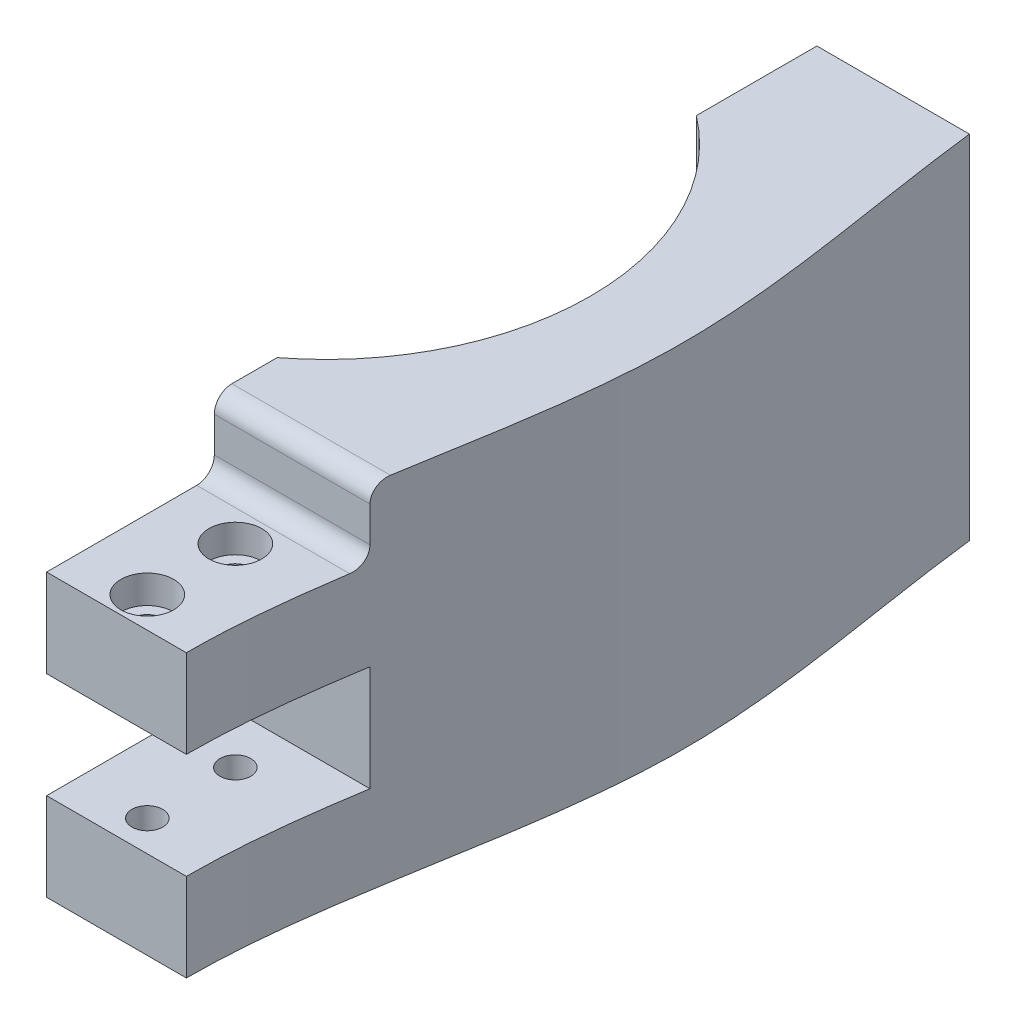
from build123d import *

# Parameters (mm, degrees)
BOSS_EXTRUDE1_DEPTH = 40
SKETCH3_W           = 12.7
SKETCH3_H           = 40
BOSS_EXTRUDE2_DEPTH = 27.178
SKETCH4_W           = 184.978795618
SKETCH4_H           = 131.733859804
CUT_EXTRUDE2_DEPTH  = 51
SKETCH5_W           = 144.166334374
SKETCH5_H           = 140.012963834
CUT_EXTRUDE3_DEPTH  = 18.25
SKETCH6_R           = 20
CUT_EXTRUDE4_DEPTH  = 20
FILLET4_R           = 3.175
SKETCH7_W           = 96.652193462
SKETCH7_H           = 93.586405028
CUT_EXTRUDE5_DEPTH  = 27.178
CUT_EXTRUDE6_DEPTH  = 41
CUT_EXTRUDE7_DEPTH  = 8
FILLET5_R           = 2
SKETCH10_R          = 1.75
CUT_EXTRUDE8_DEPTH  = 33.0000001
SKETCH11_W          = 9.551786503
SKETCH11_H          = 12
SKETCH11_W_2        = 7.9375
CUT_EXTRUDE9_DEPTH  = 19.05
SKETCH14_R          = 3
CUT_EXTRUDE10_DEPTH = 3.2
SKETCH15_W          = 61.098487026
SKETCH15_H          = 49.743772834
CUT_EXTRUDE11_DEPTH = 12.5


with BuildPart() as part:
    # Sketch1 → Boss-Extrude1 (new body)
    with BuildSketch(Plane(origin=(0, 0, 0), x_dir=(1, 0, 0), z_dir=(0, 1, 0))):
        with BuildLine():
            Line((-50, -50), (0, -50))
            Line((0, -50), (0, -30))
            ThreePointArc((0, -30), (-30, 0), (0, 30))
            Line((0, 30), (0, 50))
            Line((0, 50), (-50, 50))
            Line((-50, 50), (-50, -50))
        make_face()
        with BuildLine():
            Line((0, -30), (0, -50))
            Line((0, -50), (50, -50))
            Line((50, -50), (50, 50))
            Line((50, 50), (0, 50))
            Line((0, 50), (0, 30))
            ThreePointArc((0, 30), (21.213203436, 21.213203436), (30, 0))
            ThreePointArc((30, 0), (21.213203436, -21.213203436), (0, -30))
        make_face()
    extrude(amount=BOSS_EXTRUDE1_DEPTH)

    # Sketch3 → Boss-Extrude2 (add)
    with BuildSketch(Plane.XY.offset(50)):
        with Locations((-24.6, 20)):
            Rectangle(SKETCH3_W, SKETCH3_H)
    extrude(amount=BOSS_EXTRUDE2_DEPTH)

    # Sketch4 → Cut-Extrude2 (cut, through all)
    with BuildSketch(Plane(origin=(0, 0, 0), x_dir=(0, 0, -1), z_dir=(1, 0, 0))):
        Rectangle(SKETCH4_W, SKETCH4_H)
    extrude(amount=CUT_EXTRUDE2_DEPTH, mode=Mode.SUBTRACT)

    # Sketch5 → Cut-Extrude3 (cut)
    with BuildSketch(Plane(origin=(0, 0, 0), x_dir=(0, 0, -1), z_dir=(1, 0, 0))):
        Rectangle(SKETCH5_W, SKETCH5_H)
    extrude(amount=-CUT_EXTRUDE3_DEPTH, mode=Mode.SUBTRACT)

    # Sketch6 → Cut-Extrude4 (cut)
    with BuildSketch(Plane(origin=(0, 0, -50), x_dir=(-1, 0, 0), z_dir=(0, 0, -1))):
        with Locations((5.529693955, 22.14995336)):
            Circle(SKETCH6_R)
    extrude(amount=-CUT_EXTRUDE4_DEPTH, mode=Mode.SUBTRACT)

    # Fillet4
    fillet4_edges = [part.edges().sort_by_distance(p)[0] for p in [
        (-18.25, 6.716424466, -40),
        (-18.25, 37.583482255, -40),
    ]]
    fillet(fillet4_edges, radius=FILLET4_R)

    # Sketch7 → Cut-Extrude5 (cut)
    with BuildSketch(Plane.XY.offset(77.178)):
        Rectangle(SKETCH7_W, SKETCH7_H)
    extrude(amount=-CUT_EXTRUDE5_DEPTH, mode=Mode.SUBTRACT)

    # Sketch8 → Cut-Extrude6 (cut, through all)
    with BuildSketch(Plane(origin=(0, 40, 0), x_dir=(1, 0, 0), z_dir=(0, 1, 0))):
        with BuildLine():
            Line((-34.76, 50), (-50, 50))
            Line((-50, 50), (-50, -50))
            Line((-50, -50), (-34.125, -50))
            add(Edge.make_bspline(
                [(-34.125, -50), (-34.125, -33.241229213), (-45.237036485, -0.093705418), (-34.76, 33.330216103), (-34.76, 50)],
                knots=[0, 0, 0, 0, 0.500369617, 1, 1, 1, 1], degree=3))
        make_face()
    extrude(amount=-CUT_EXTRUDE6_DEPTH, mode=Mode.SUBTRACT)

    # Sketch9 → Cut-Extrude7 (cut)
    with BuildSketch(Plane(origin=(0, 40, 0), x_dir=(1, 0, 0), z_dir=(0, 1, 0))):
        with BuildLine():
            Line((-18.25, -50), (-18.25, -30.95))
            Line((-18.25, -30.95), (-35.932995014, -30.95))
            add(Edge.make_bspline(
                [(-34.125, -50), (-34.125, -43.629466822), (-34.928437006, -37.283896996), (-35.932995014, -30.95)],
                knots=[0, 0, 0, 0, 0.190206149, 0.190206149, 0.190206149, 0.190206149], degree=3))
            Line((-34.125, -50), (-18.25, -50))
        make_face()
    extrude(amount=-CUT_EXTRUDE7_DEPTH, mode=Mode.SUBTRACT)

    # Fillet5
    fillet5_edges = [part.edges().sort_by_distance(p)[0] for p in [
        (-27.091497507, 32, 30.95),
        (-27.091497507, 40, 30.95),
    ]]
    fillet(fillet5_edges, radius=FILLET5_R)

    # Sketch10 → Cut-Extrude8 (cut, through all)
    with BuildSketch(Plane(origin=(0, 32, 0), x_dir=(1, 0, 0), z_dir=(0, 1, 0))):
        with Locations((-26.1875, -46.5)):
            Circle(SKETCH10_R)
        with Locations((-26.1875, -36.5)):
            Circle(SKETCH10_R)
    extrude(amount=-CUT_EXTRUDE8_DEPTH, mode=Mode.SUBTRACT)

    # Sketch11 → Cut-Extrude9 (cut)
    with BuildSketch(Plane.XY.offset(50)):
        with Locations((-38.900893252, 16)):
            Rectangle(SKETCH11_W, SKETCH11_H)
        with Locations((-30.15625, 16)):
            Rectangle(SKETCH11_W_2, SKETCH11_H)
        with Locations((-22.21875, 16)):
            Rectangle(SKETCH11_W_2, SKETCH11_H)
    extrude(amount=-CUT_EXTRUDE9_DEPTH, mode=Mode.SUBTRACT)

    # Sketch14 → Cut-Extrude10 (cut)
    with BuildSketch(Plane(origin=(0, 32, 0), x_dir=(1, 0, 0), z_dir=(0, 1, 0))):
        with Locations((-26.1875, -36.5)):
            Circle(SKETCH14_R)
        with Locations((-26.1875, -46.5)):
            Circle(SKETCH14_R)
    cut_extrude10 = extrude(amount=-CUT_EXTRUDE10_DEPTH, mode=Mode.SUBTRACT)

    # Mirror2: Cut-Extrude10 across plane
    add(cut_extrude10.mirror(Plane.ZX.offset(16)), mode=Mode.SUBTRACT)

    # Sketch15 → Cut-Extrude11 (cut)
    with BuildSketch(Plane(origin=(0, 0, -50), x_dir=(-1, 0, 0), z_dir=(0, 0, -1))):
        with Locations((30.549243513, 24.871886417)):
            Rectangle(SKETCH15_W, SKETCH15_H)
    extrude(amount=-CUT_EXTRUDE11_DEPTH, mode=Mode.SUBTRACT)


with BuildPart() as body_2:
    # Mirror3: mirrored copy
    add(part.part.mirror(Plane(origin=(0, 0, 0), x_dir=(0, 0, 1), z_dir=(1, 0, 0))))


solid = body_2.part
